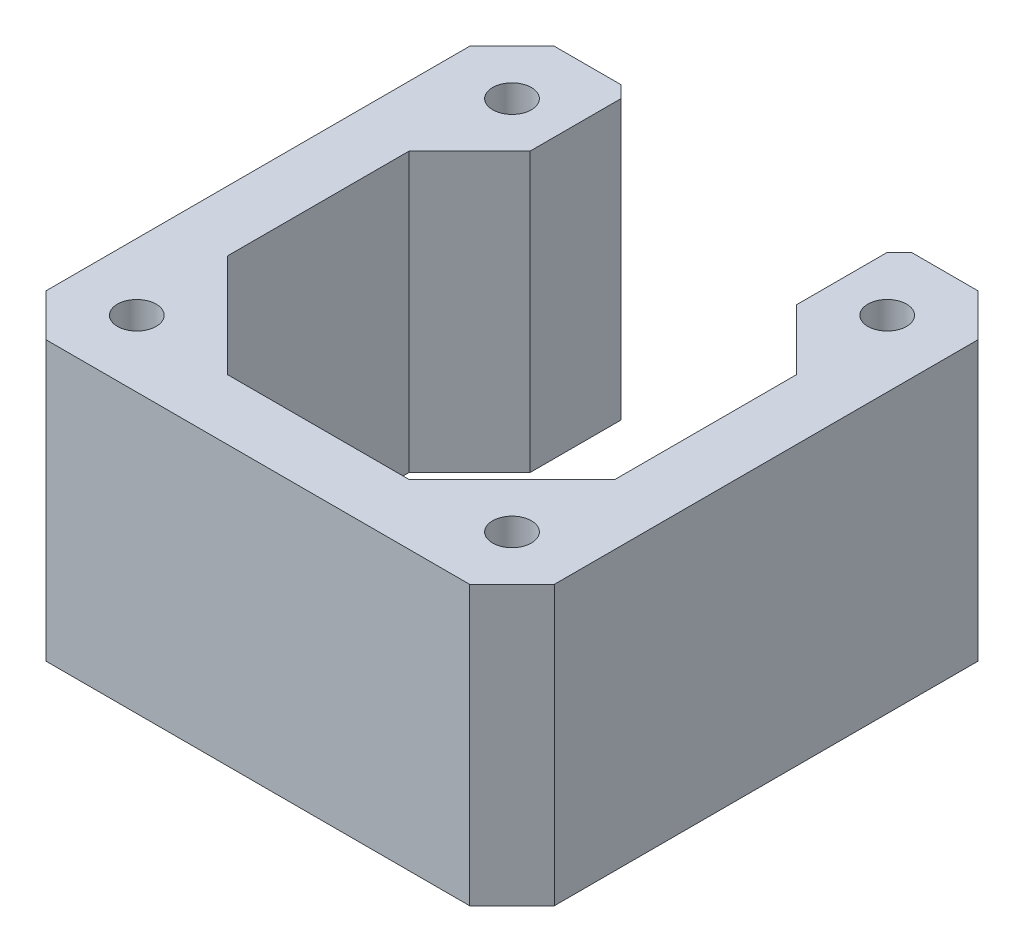
from build123d import *

# Parameters (mm, degrees)
SKETCH1_R       = 1.6
BASE_DEPTH      = 23
BASE_DEPTH_BACK = 0.0001


with BuildPart() as part:
    # Sketch1 → Base (new body, two sides)
    with BuildSketch(Plane(origin=(0, 0, 0), x_dir=(1, 0, 0), z_dir=(0, 1, 0))) as base_sk:
        Polygon((-16, -7.499999998), (-7.5, -15.999999998), (7.5, -15.999999998), (16, -7.499999998), (16, 7.500000002), (11, 12.500000002), (11, 20.000000005), (12, 21.000000005), (17.500000004, 21.000000005), (21, 17.500000009), (21, -17.499999998), (17.5, -20.999999998), (-17.5, -20.999999998), (-21, -17.499999998), (-21, 17.500000009), (-17.500000004, 21.000000005), (-12, 21.000000005), (-11, 20.000000005), (-11, 12.500000002), (-16, 7.500000002), align=None)
        with Locations((-15.500000002, 15.5)):
            Circle(SKETCH1_R, mode=Mode.SUBTRACT)
        with Locations((-15.500000002, -15.5)):
            Circle(SKETCH1_R, mode=Mode.SUBTRACT)
        with Locations((15.500000002, -15.5)):
            Circle(SKETCH1_R, mode=Mode.SUBTRACT)
        with Locations((15.500000002, 15.5)):
            Circle(SKETCH1_R, mode=Mode.SUBTRACT)
    extrude(amount=BASE_DEPTH)
    extrude(base_sk.sketch, amount=-BASE_DEPTH_BACK)


solid = part.part
